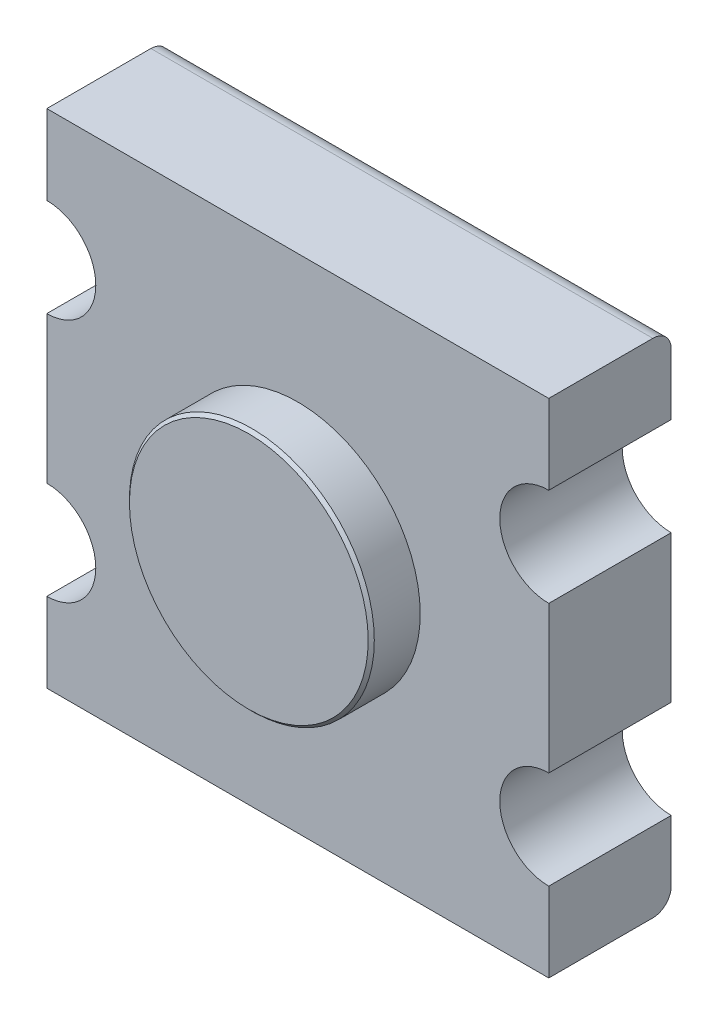
from build123d import *

# Parameters (mm, degrees)
BOSS_EXTRUDE1_DEPTH = 20
SKETCH2_R           = 20
BOSS_EXTRUDE2_DEPTH = 8
CHAMFER1_SIZE       = 0.5
FILLET1_R           = 3


with BuildPart() as part:
    # Sketch1 → Boss-Extrude1 (new body)
    with BuildSketch(Plane.XY):
        with BuildLine():
            Line((0, 69), (0, 82))
            Line((0, 82), (82, 82))
            Line((82, 82), (82, 69))
            ThreePointArc((82, 69), (74, 61), (82, 53))
            Line((82, 53), (82, 29))
            ThreePointArc((82, 29), (74, 21), (82, 13))
            Line((82, 13), (82, 0))
            Line((82, 0), (0, 0))
            Line((0, 0), (0, 13))
            ThreePointArc((0, 13), (8, 21), (0, 29))
            Line((0, 29), (0, 53))
            ThreePointArc((0, 53), (8, 61), (0, 69))
        make_face()
    extrude(amount=BOSS_EXTRUDE1_DEPTH)

    # Sketch2 → Boss-Extrude2 (add)
    with BuildSketch(Plane.XY.offset(20)):
        with Locations((41, 41)):
            Circle(SKETCH2_R)
    extrude(amount=BOSS_EXTRUDE2_DEPTH)

    # Chamfer1
    chamfer1_edges = [part.edges().sort_by_distance(p)[0] for p in [
        (21, 41, 28),
    ]]
    chamfer(chamfer1_edges, length=CHAMFER1_SIZE)

    # Fillet1
    fillet1_edges = [part.edges().sort_by_distance(p)[0] for p in [
        (41, 82, 0),
        (41, 0, 0),
    ]]
    fillet(fillet1_edges, radius=FILLET1_R)


solid = part.part
